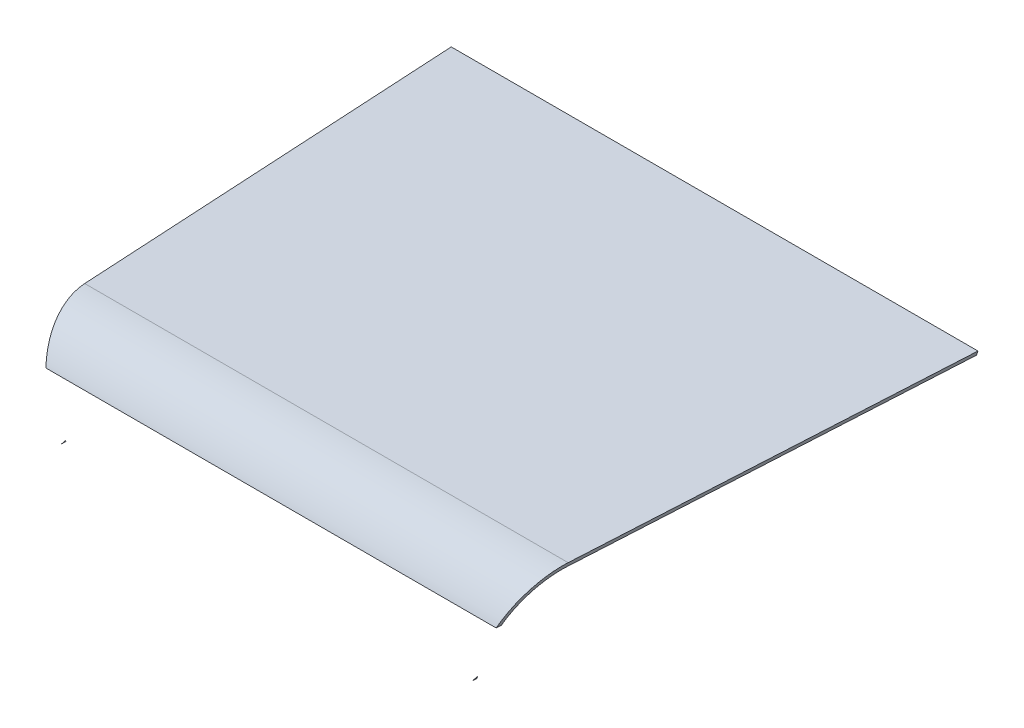
from build123d import *

# Parameters (mm, degrees)
FILLET1_R          = 40
SHELL2_T           = -3
CUT_EXTRUDE1_DEPTH = 30


with BuildPart() as part:
    # Sketch2 → Loft1 section 0
    with BuildSketch(Plane.XY.offset(-300)):
        Polygon((-154.231358145, 189.098565855), (154.231358145, 189.098565855), (176.397667398, 250), (-176.397667398, 250), align=None)
    # Sketch1 → Loft1 section 1
    with BuildSketch(Plane.XY):
        Polygon((-159.666309253, 250), (-137.5, 189.098565855), (137.5, 189.098565855), (159.666309253, 250), align=None)
    loft()

    # Fillet1
    fillet1_edges = [part.edges().sort_by_distance(p)[0] for p in [
        (0, 250, 0),
    ]]
    fillet(fillet1_edges, radius=FILLET1_R)

    # Shell2
    shell2_openings = [part.faces().sort_by_distance(p)[0] for p in [
        (0, 219.549282927, -300),
        (-159.448338541, 221.819713171, -180),
        (-72.932839536, 189.098565855, -225),
        (156.851508139, 213.459139513, -188),
    ]]
    offset(amount=SHELL2_T, openings=shell2_openings, kind=Kind.INTERSECTION)

    # Sketch4 → Cut-Extrude1 (cut)
    with BuildSketch(Plane.XY):
        Polygon((-137.5, 189.098565855), (137.5, 189.098565855), (154.249008644, 225.058565855), (-165.371779032, 225.058565855), align=None)
    extrude(amount=-CUT_EXTRUDE1_DEPTH, mode=Mode.SUBTRACT)


solid = part.part
